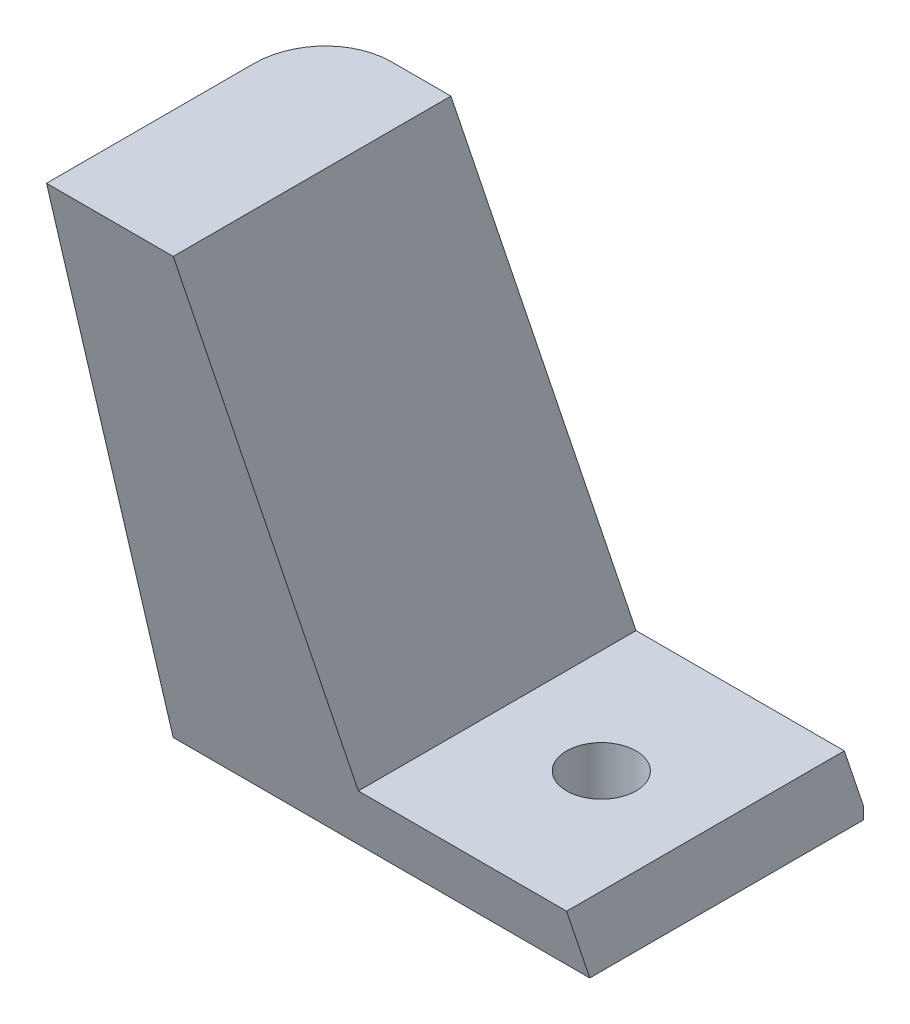
from build123d import *

# Parameters (mm, degrees)
EXTRUDE_8_DEPTH     = 50
CUT_EXTRUDE_3_DEPTH = 60
EXTRUDE_5_DEPTH     = 15
SKETCH_6_R          = 2.5
CUT_EXTRUDE_4_DEPTH = 15
FILLET_3_R          = 5


with BuildPart() as part:
    # Эскиз2 → Бобышка-Вытянуть8 (new body)
    with BuildSketch(Plane.XY):
        Polygon((-39.125, 45), (-30, 45), (-30, 0), (-45, 0), align=None)
    extrude(amount=-EXTRUDE_8_DEPTH)

    # Эскиз4 → Вырез-Вытянуть3 (cut)
    with BuildSketch(Plane(origin=(0, 0, 0), x_dir=(0, 0, -1), z_dir=(1, 0, 0))):
        Polygon((50.288969981, 0), (35.288969981, 45), (50, 45), align=None)
        Polygon((0, 45), (0, 0), (30.288969981, 0), (15.293288519, 45), align=None)
    extrude(amount=-CUT_EXTRUDE_3_DEPTH, mode=Mode.SUBTRACT)

    # Эскиз5 → Бобышка-Вытянуть5 (add)
    with BuildSketch(Plane(origin=(-30, 0, 0), x_dir=(0, 0, -1), z_dir=(1, 0, 0))):
        Polygon((50, 0), (50, 0.866909943), (48.622303314, 5), (28.622783152, 5), (30.288969981, 0), align=None)
    extrude(amount=EXTRUDE_5_DEPTH)

    # Эскиз6 → Вырез-Вытянуть4 (cut)
    with BuildSketch(Plane(origin=(0, 5, 0), x_dir=(1, 0, 0), z_dir=(0, 1, 0))):
        with Locations((-22.5, 38.622543233)):
            Circle(SKETCH_6_R)
    extrude(amount=-CUT_EXTRUDE_4_DEPTH, mode=Mode.SUBTRACT)

    # Скругление3
    fillet_3_edges = [part.edges().sort_by_distance(p)[0] for p in [
        (-42.005910045, 22.933454971, -42.64448499),
    ]]
    fillet(fillet_3_edges, radius=FILLET_3_R)


solid = part.part
